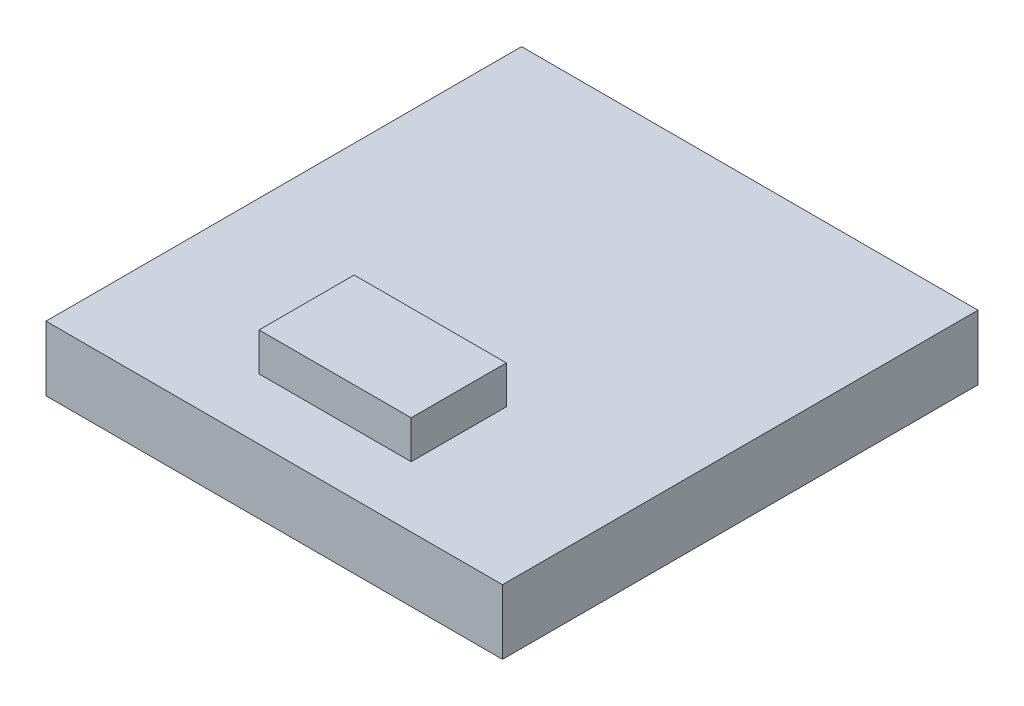
from build123d import *

# Parameters (mm, degrees)
SKETCH1_W           = 6
SKETCH1_H           = 6.25
BOSS_EXTRUDE1_DEPTH = 0.85
SKETCH2_W           = 2
SKETCH2_H           = 1.25
BOSS_EXTRUDE2_DEPTH = 0.5


with BuildPart() as part:
    # Sketch1 → Boss-Extrude1 (new body)
    with BuildSketch(Plane(origin=(0, 0, 0), x_dir=(1, 0, 0), z_dir=(0, 1, 0))):
        Rectangle(SKETCH1_W, SKETCH1_H)
    extrude(amount=BOSS_EXTRUDE1_DEPTH)

    # Sketch2 → Boss-Extrude2 (add)
    with BuildSketch(Plane(origin=(0, 0.85, 0), x_dir=(1, 0, 0), z_dir=(0, 1, 0))):
        with Locations((0, -1.7)):
            Rectangle(SKETCH2_W, SKETCH2_H)
    extrude(amount=BOSS_EXTRUDE2_DEPTH)


solid = part.part
